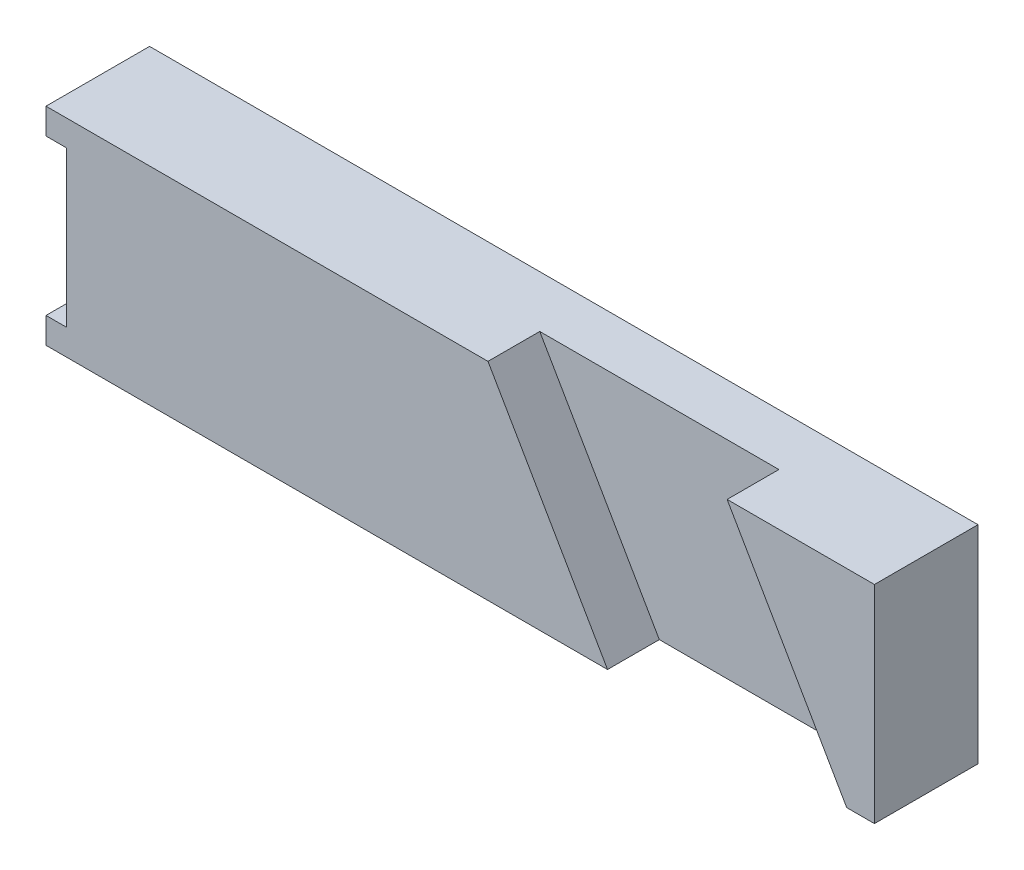
from build123d import *

# Parameters (mm, degrees)
EXTRUDE_1_DEPTH     = 10
CUT_EXTRUDE_1_DEPTH = 5


with BuildPart() as part:
    # 草圖2 → 填料-伸長1 (new body)
    with BuildSketch(Plane.XY):
        Polygon((-40, 7.5), (-38, 7.5), (-38, -7.5), (-40, -7.5), (-40, -10), (40, -10), (40, 10), (-40, 10), align=None)
    extrude(amount=EXTRUDE_1_DEPTH)

    # 草圖3 → 除料-伸長1 (cut)
    with BuildSketch(Plane.XY.offset(10)):
        Polygon((2.679491924, 10), (14.226497308, -10), (37.320508076, -10), (25.773502692, 10), align=None)
    extrude(amount=-CUT_EXTRUDE_1_DEPTH, mode=Mode.SUBTRACT)


solid = part.part
